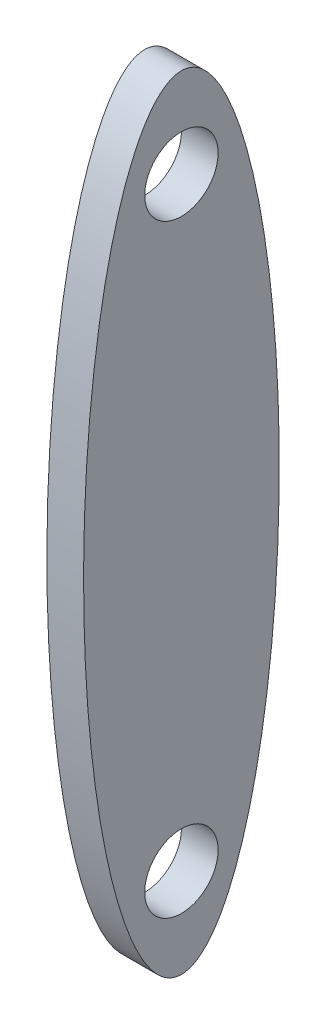
from build123d import *

# Parameters (mm, degrees)
SKETCH2_RX          = 50.8
SKETCH2_RY          = 12.7
BOSS_EXTRUDE1_DEPTH = 4.7625
SKETCH3_R           = 4.7625
CUT_EXTRUDE1_DEPTH  = 5.7625
SKETCH4_R           = 4.7625
CUT_EXTRUDE10_DEPTH = 5.7625


with BuildPart() as part:
    # Sketch2 → Boss-Extrude1 (new body)
    with BuildSketch(Plane(origin=(0, 0, 0), x_dir=(0, 0, -1), z_dir=(1, 0, 0))):
        with Locations(Location((0, 0), (0, 0, 90))):
            Ellipse(SKETCH2_RX, SKETCH2_RY)
    extrude(amount=BOSS_EXTRUDE1_DEPTH)

    # Sketch3 → Cut-Extrude1 (cut, through all)
    with BuildSketch(Plane(origin=(4.7625, 0, 0), x_dir=(0, 0, -1), z_dir=(1, 0, 0))):
        with Locations((0, 39.176379409)):
            Circle(SKETCH3_R)
    extrude(amount=-CUT_EXTRUDE1_DEPTH, mode=Mode.SUBTRACT)

    # Sketch4 → Cut-Extrude10 (cut, through all)
    with BuildSketch(Plane(origin=(0, 0, 0), x_dir=(0, 0, -1), z_dir=(1, 0, 0))):
        with Locations((0, -39.1763758)):
            Circle(SKETCH4_R)
    extrude(amount=CUT_EXTRUDE10_DEPTH, mode=Mode.SUBTRACT)


solid = part.part
